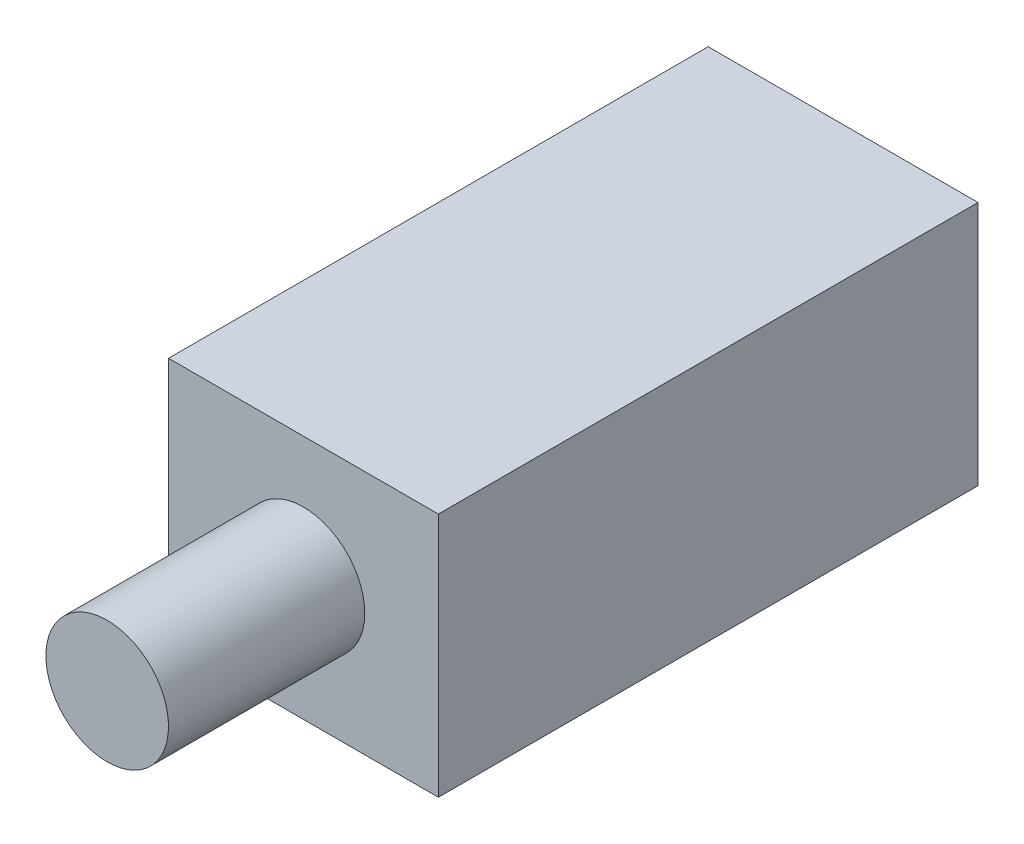
from build123d import *

# Parameters (mm, degrees)
SKIZZE1_W               = 11
SKIZZE1_H               = 10
LINEAR_AUSTRAGEN1_DEPTH = 22
SKIZZE2_R               = 2.5
LINEAR_AUSTRAGEN2_DEPTH = 8


with BuildPart() as part:
    # Skizze1 → Linear austragen1 (new body)
    with BuildSketch(Plane.XY):
        with Locations((0, 5)):
            Rectangle(SKIZZE1_W, SKIZZE1_H)
    extrude(amount=-LINEAR_AUSTRAGEN1_DEPTH)

    # Skizze2 → Linear austragen2 (add)
    with BuildSketch(Plane.XY):
        with Locations((0, 5)):
            Circle(SKIZZE2_R)
    extrude(amount=LINEAR_AUSTRAGEN2_DEPTH)


solid = part.part
